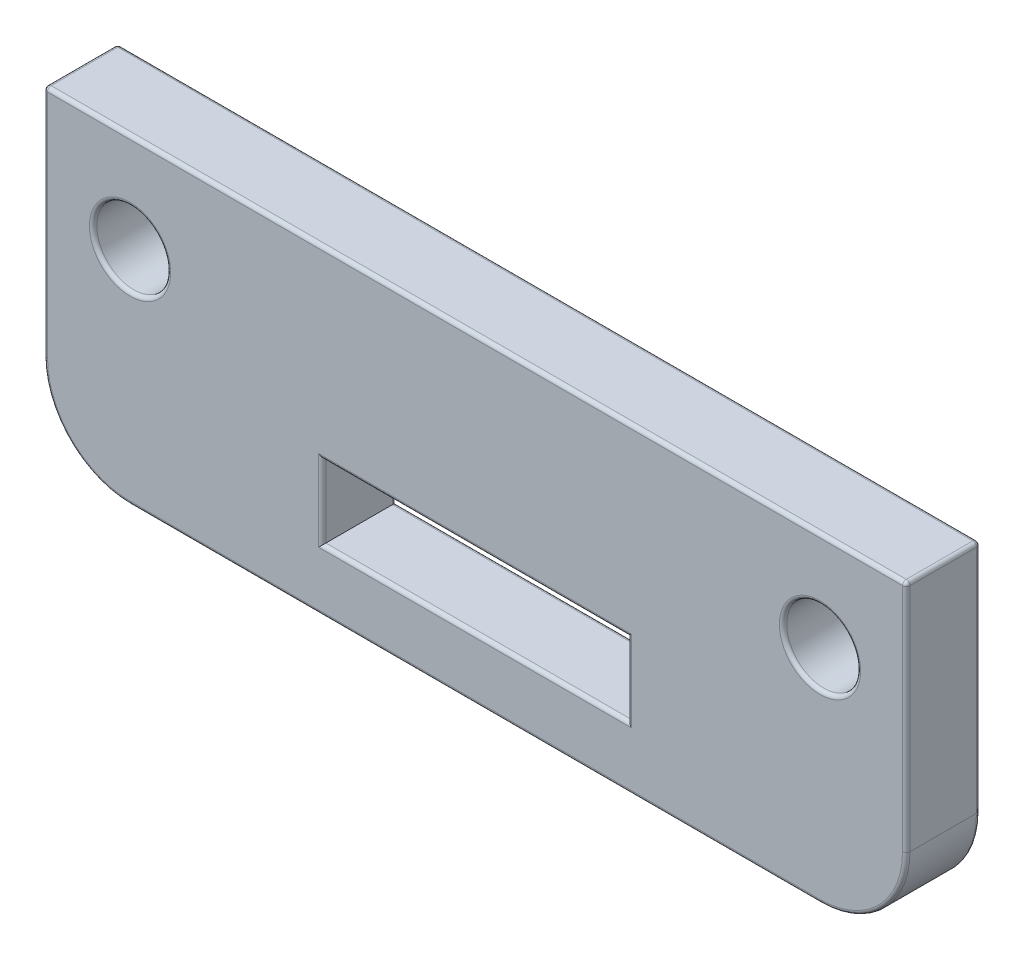
from build123d import *

# Parameters (mm, degrees)
SKETCH1_R               = 1
SKETCH1_R_2             = 1.5
SKETCH1_R_3             = 2
SKETCH1_W               = 23
SKETCH1_H               = 12
SKETCH1_W_2             = 12.4
SKETCH1_H_2             = 3
BOSS_EXTRUDE1_DEPTH     = 3
FILLET1_R               = 3.5
CUT_EXTRUDE1_DEPTH      = 1
CUT_EXTRUDE1_DEPTH_BACK = 4
FILLET3_R               = 0.15


with BuildPart() as part:
    # Sketch1 → Boss-Extrude1 (new body)
    with BuildSketch(Plane.XY):
        with BuildLine():
            Line((-17.5, 9), (-17.5, -19))
            Line((-17.5, -19), (17.5, -19))
            Line((17.5, -19), (17.5, 9))
            ThreePointArc((17.5, 9), (0, 26), (-17.5, 9))
        make_face()
        with Locations((-14, 0)):
            Circle(SKETCH1_R, mode=Mode.SUBTRACT)
        with Locations((-14, -10)):
            Circle(SKETCH1_R_2, mode=Mode.SUBTRACT)
        with Locations((-8.5, 16)):
            Circle(SKETCH1_R_3, mode=Mode.SUBTRACT)
        with Locations((14, -10)):
            Circle(SKETCH1_R_2, mode=Mode.SUBTRACT)
        with Locations((14, 0)):
            Circle(SKETCH1_R, mode=Mode.SUBTRACT)
        with Locations((8.5, 16)):
            Circle(SKETCH1_R_3, mode=Mode.SUBTRACT)
        Rectangle(SKETCH1_W, SKETCH1_H, mode=Mode.SUBTRACT)
        with Locations((0, -15)):
            Rectangle(SKETCH1_W_2, SKETCH1_H_2, mode=Mode.SUBTRACT)
    extrude(amount=BOSS_EXTRUDE1_DEPTH)

    # Fillet1
    fillet1_edges = [part.edges().sort_by_distance(p)[0] for p in [
        (17.5, -19, 1.5),
        (-17.5, -19, 1.5),
    ]]
    fillet(fillet1_edges, radius=FILLET1_R)

    # Sketch2 → Cut-Extrude1 (cut, two sides)
    with BuildSketch(Plane.XY.offset(3)) as cut_extrude1_sk:
        Polygon((-142.935501538, -6), (-22.5, -6), (27.5, -6), (147.935501538, -6), (147.935501538, 234.871003076), (-142.935501538, 234.871003076), align=None)
    extrude(amount=CUT_EXTRUDE1_DEPTH, mode=Mode.SUBTRACT)
    extrude(cut_extrude1_sk.sketch, amount=-CUT_EXTRUDE1_DEPTH_BACK, mode=Mode.SUBTRACT)

    # Fillet3
    fillet3_edges = [part.edges().sort_by_distance(p)[0] for p in [
        (0, -6, 0),
        (0, -6, 3),
        (-15.5, -10, 0),
        (-15.5, -10, 3),
        (-6.2, -15, 0),
        (0, -16.5, 0),
        (6.2, -15, 0),
        (0, -13.5, 0),
        (-6.2, -15, 3),
        (0, -16.5, 3),
        (6.2, -15, 3),
        (0, -13.5, 3),
        (12.5, -10, 0),
        (12.5, -10, 3),
        (17.5, -10.75, 0),
        (17.5, -10.75, 3),
        (0, -19, 0),
        (-16.474873734, -17.974873734, 0),
        (16.474873734, -17.974873734, 0),
        (0, -19, 3),
        (-16.474873734, -17.974873734, 3),
        (16.474873734, -17.974873734, 3),
        (-17.5, -10.75, 0),
        (-17.5, -10.75, 3),
        (-17.5, -6, 1.5),
        (17.5, -6, 1.5),
    ]]
    fillet(fillet3_edges, radius=FILLET3_R)


solid = part.part
